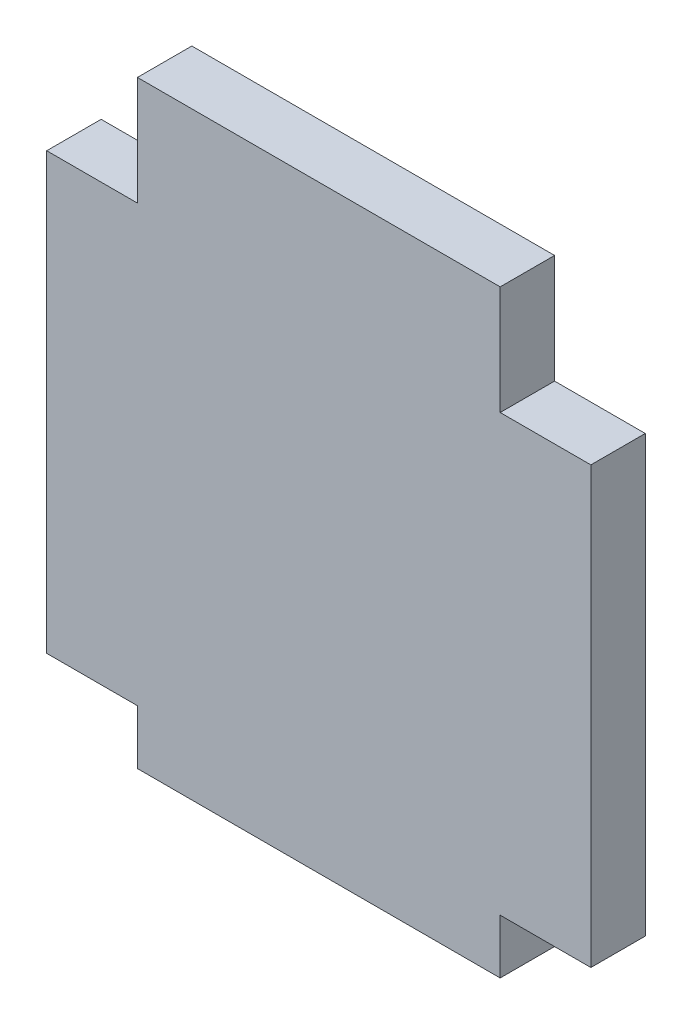
from build123d import *

# Parameters (mm, degrees)
ESBO_O1_W                = 30
ESBO_O1_H                = 24
ESBO_O1_W_2              = 20
ESBO_O1_H_2              = 6
ESBO_O1_H_3              = 3
RESSALTO_EXTRUS_O1_DEPTH = 3


with BuildPart() as part:
    # Esboço1 → Ressalto-extrusão1 (new body)
    with BuildSketch(Plane.XY):
        Rectangle(ESBO_O1_W, ESBO_O1_H)
        with Locations((0, 15)):
            Rectangle(ESBO_O1_W_2, ESBO_O1_H_2)
        with Locations((0, -13.5)):
            Rectangle(ESBO_O1_W_2, ESBO_O1_H_3)
    extrude(amount=RESSALTO_EXTRUS_O1_DEPTH)


solid = part.part
